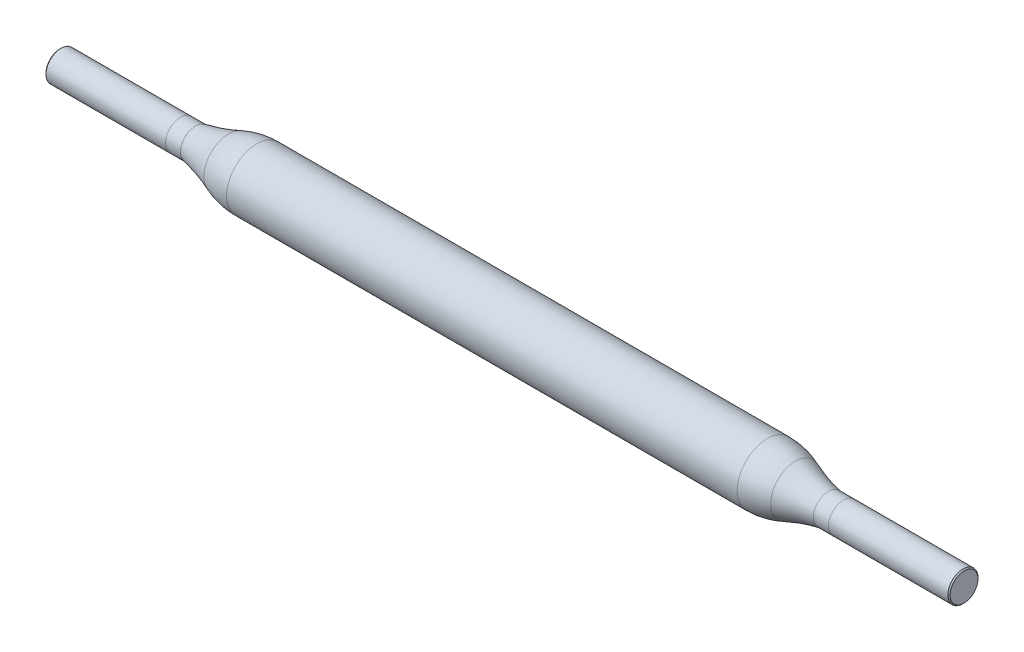
from build123d import *

# Parameters (mm, degrees)
CHAMFER1_SIZE = 0.075


with BuildPart() as part:
    # Sketch2 → Revolve1 (revolve)
    with BuildSketch(Plane.XY):
        with BuildLine():
            Line((-30, 0), (30, 0))
            Line((30, 0), (30, 1))
            Line((30, 1), (21, 1))
            ThreePointArc((21, 1), (19.887839476, 1.264702229), (18.807410064, 1.638387373))
            ThreePointArc((18.807410064, 1.638387373), (17.891303231, 1.908764451), (16.940497485, 2))
            Line((16.940497485, 2), (-16.940497485, 2))
            ThreePointArc((-16.940497485, 2), (-17.891303231, 1.908764451), (-18.807410064, 1.638387373))
            ThreePointArc((-18.807410064, 1.638387373), (-19.887839476, 1.264702229), (-21, 1))
            Line((-21, 1), (-30, 1))
            Line((-30, 1), (-30, 0))
        make_face()
    revolve(axis=Axis((-30, 0, 0), (1, 0, 0)))

    # Chamfer1
    chamfer1_edges = [part.edges().sort_by_distance(p)[0] for p in [
        (30, -1, 0),
        (-30, -1, 0),
    ]]
    chamfer(chamfer1_edges, length=CHAMFER1_SIZE)


solid = part.part
